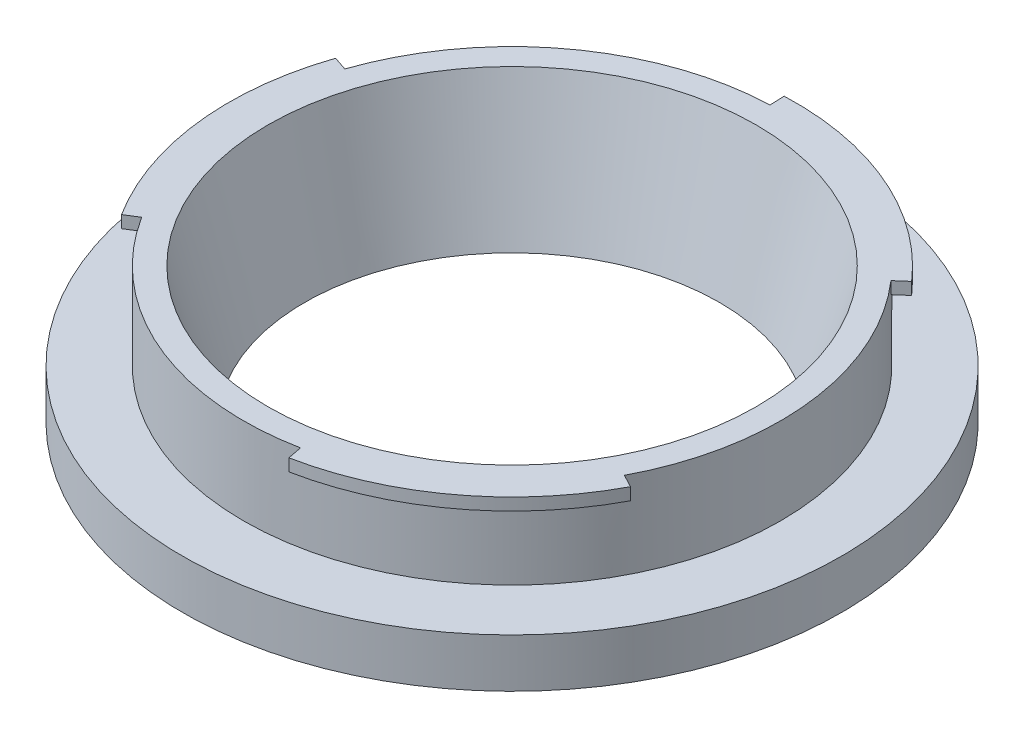
from build123d import *
from build123d.topology import SkipClean

# Parameters (mm, degrees)
SKETCH1_W          = 2
SKETCH1_H          = 11.1
SKETCH1_W_2        = 5
SKETCH1_H_2        = 4
SKETCH1_W_3        = 1.2
SKETCH1_H_3        = 1
CUT_EXTRUDE1_DEPTH = 1


with BuildPart() as part:
    # Sketch1 → Revolve1 (revolve)
    with BuildSketch(Plane.XY, mode=Mode.PRIVATE) as revolve1_sk:
        with Locations((21, 5.55)):
            Rectangle(SKETCH1_W, SKETCH1_H)
        with Locations((24.5, 2)):
            Rectangle(SKETCH1_W_2, SKETCH1_H_2)
        with Locations((22.6, 10.6)):
            Rectangle(SKETCH1_W_3, SKETCH1_H_3)
        Polygon((17, 0), (20, 11.1), (20, 0), align=None)
    revolve(revolve1_sk.sketch.rotate(Axis((0, 0, 0), (0, 1, 0)), 90), axis=Axis((0, 0, 0), (0, 1, 0)))  # turned: the seam where the file's is

    # Sketch3 → Cut-Extrude1 (cut)
    with SkipClean():  # keep this step's faces unmerged: merging them makes the solid invalid here
        with BuildSketch(Plane(origin=(0, 11.1, 0), x_dir=(1, 0, 0), z_dir=(0, 1, 0))):
            with BuildLine():
                ThreePointArc((23.2, 0), (21.721311586, 8.150130242), (17.473739399, 15.261337799))
                Line((17.473739399, 15.261337799), (16.569925293, 14.471958257))
                ThreePointArc((16.569925293, 14.471958257), (20.59779547, 7.728571782), (22, 0))
                ThreePointArc((22, 0), (21.355762595, -5.285016934), (19.460781455, -10.260506087))
                Line((19.460781455, -10.260506087), (20.522278625, -10.820170056))
                ThreePointArc((20.522278625, -10.820170056), (22.520622373, -5.573290585), (23.2, 0))
            make_face()
            with BuildLine():
                Line((-18.616249655, -11.723278074), (-19.631681454, -12.362729605))
                ThreePointArc((-19.631681454, -12.362729605), (-9.18901176, -21.302630421), (4.47983653, -22.763371118))
                Line((4.47983653, -22.763371118), (4.248120847, -21.585955371))
                ThreePointArc((4.248120847, -21.585955371), (-8.713718048, -20.200770227), (-18.616249655, -11.723278074))
            make_face()
            with BuildLine():
                Line((-0.8445318, 21.983784161), (-0.890597171, 23.182899661))
                ThreePointArc((-0.890597171, 23.182899661), (-13.854113232, 18.609232831), (-21.953575929, 7.50203332))
                Line((-21.953575929, 7.50203332), (-20.81804614, 7.113997113))
                ThreePointArc((-20.81804614, 7.113997113), (-13.137521169, 17.646686305), (-0.8445318, 21.983784161))
            make_face()
        extrude(amount=-CUT_EXTRUDE1_DEPTH, mode=Mode.SUBTRACT)


solid = part.part
